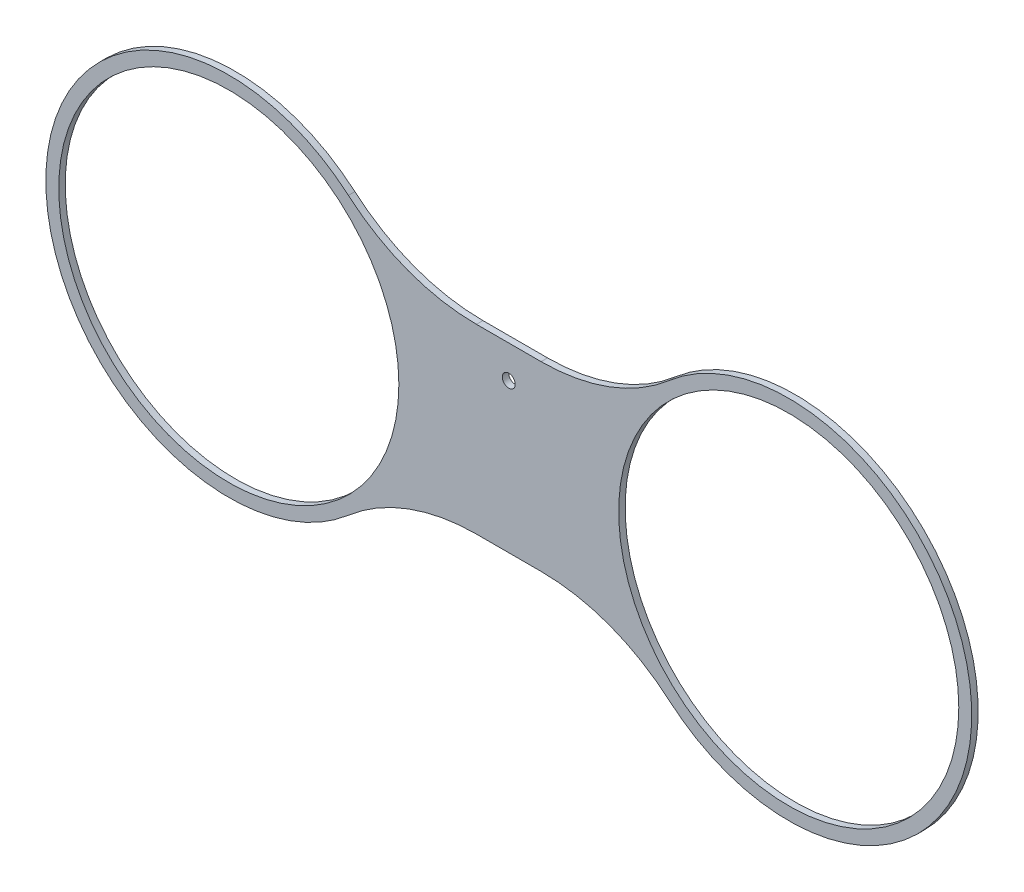
from build123d import *

# Parameters (mm, degrees)
SKETCH1_R           = 83.4771
SKETCH1_R_2         = 3.175
BOSS_EXTRUDE1_DEPTH = 3.175


with BuildPart() as part:
    # Sketch1 → Boss-Extrude1 (new body)
    with BuildSketch(Plane.XY):
        with BuildLine():
            Line((-15.854735322, -44.594342032), (15.852600775, -44.594342032))
            ThreePointArc((15.852600775, -44.594342032), (49.382027762, -50.630069264), (78.701832464, -67.979464917))
            ThreePointArc((78.701832464, -67.979464917), (227.246053, 0), (78.701832464, 67.979464917))
            ThreePointArc((78.701832464, 67.979464917), (49.382027762, 50.630069264), (15.852600775, 44.594342032))
            Line((15.852600775, 44.594342032), (-15.854735322, 44.594342032))
            ThreePointArc((-15.854735322, 44.594342032), (-49.384162309, 50.630069264), (-78.703967011, 67.979464917))
            ThreePointArc((-78.703967011, 67.979464917), (-227.248187547, 0), (-78.703967011, -67.979464917))
            ThreePointArc((-78.703967011, -67.979464917), (-49.384162309, -50.630069264), (-15.854735322, -44.594342032))
        make_face()
        with Locations((137.418953, 0)):
            Circle(SKETCH1_R, mode=Mode.SUBTRACT)
        with Locations((-137.421087547, 0)):
            Circle(SKETCH1_R, mode=Mode.SUBTRACT)
        with Locations((0, 28.575000036)):
            Circle(SKETCH1_R_2, mode=Mode.SUBTRACT)
    extrude(amount=BOSS_EXTRUDE1_DEPTH)


solid = part.part
